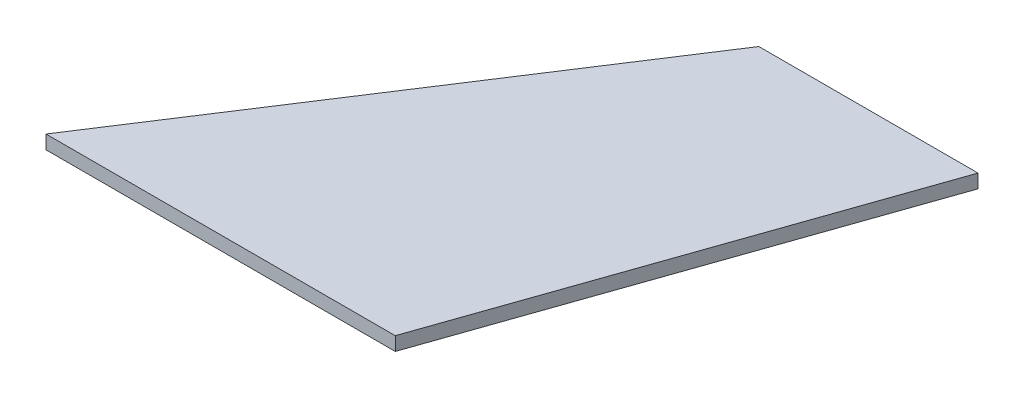
from build123d import *

# Parameters (mm, degrees)
BOSS_EXTRUDE1_DEPTH = 1


with BuildPart() as part:
    # Sketch1 → Boss-Extrude1 (new, symmetric)
    with BuildSketch(Plane(origin=(0, 0, 0), x_dir=(1, 0, 0), z_dir=(0, 1, 0))):
        Polygon((0, 0), (51, 0), (72.983717202, 63.109390206), (40.983717202, 63.109390206), align=None)
    extrude(amount=BOSS_EXTRUDE1_DEPTH, both=True)


solid = part.part
